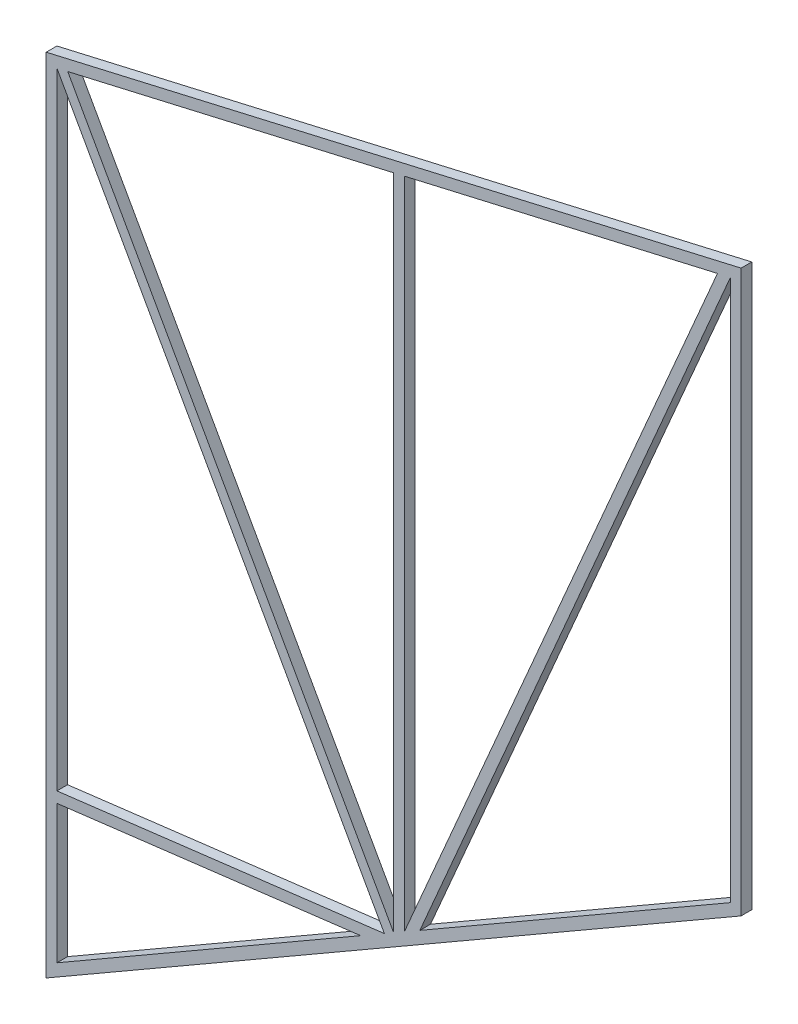
from build123d import *

# Parameters (mm, degrees)
EXTRUDE_1_DEPTH = 2


with BuildPart() as part:
    # ｽｹｯﾁ1 → ﾎﾞｽ - 押し出し1 (new body)
    with BuildSketch(Plane.XY):
        Polygon((130, 75.055534995), (0, 0), (0, 150), (130, 180.012864846), align=None)
        Polygon((128, 76.210235533), (2, 3.464101615), (2, 148.409128167), (128, 177.498520248), align=None, mode=Mode.SUBTRACT)
        Polygon((67, 163.41556059), (65, 162.953824208), (65, 39.837168574), (67, 40.991869112), align=None)
        Polygon((4.029439999, 148.877661308), (2, 148.409128167), (63.267785356, 38.837073983), (65, 39.837168574), align=None)
        Polygon((125.581629022, 176.940195315), (67, 40.991869112), (69.899019864, 42.665619011), (128, 177.498520248), align=None)
        Polygon((63.267785356, 38.837073983), (2, 31.314335861), (2, 29.29931621), (58.834939644, 36.277769318), align=None)
    extrude(amount=EXTRUDE_1_DEPTH)


solid = part.part
